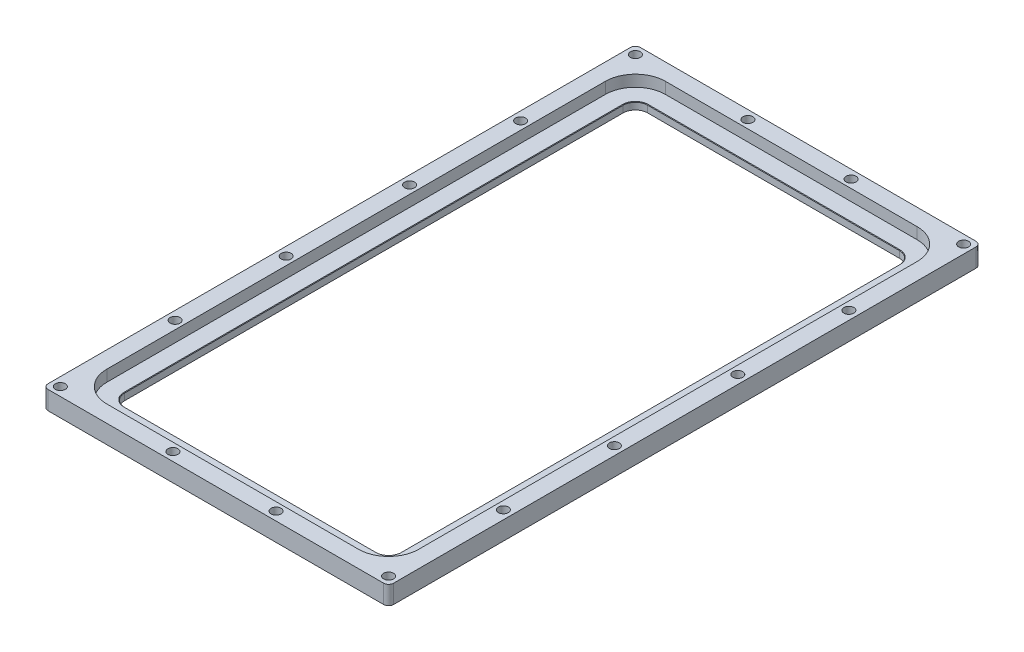
from build123d import *

# Parameters (mm, degrees)
SKETCH1_W           = 177.8
SKETCH1_H           = 304.8
BOSS_EXTRUDE1_DEPTH = 9.525
SKETCH2_W           = 142.24
SKETCH2_H           = 269.24
CUT_EXTRUDE1_DEPTH  = 10.525
SKETCH3_R           = 2.5527
CUT_EXTRUDE2_DEPTH  = 10.525
FILLET4_R           = 6.35
CUT_EXTRUDE5_DEPTH  = 5.842
CHAMFER1_SIZE       = 0.254
FILLET5_R           = 2.54


with BuildPart() as part:
    # Sketch1 → Boss-Extrude1 (new body)
    with BuildSketch(Plane(origin=(0, 0, 0), x_dir=(1, 0, 0), z_dir=(0, 1, 0))):
        with Locations((88.9, 152.4)):
            Rectangle(SKETCH1_W, SKETCH1_H)
    extrude(amount=BOSS_EXTRUDE1_DEPTH)

    # Sketch2 → Cut-Extrude1 (cut, through all)
    with BuildSketch(Plane(origin=(0, 9.525, 0), x_dir=(1, 0, 0), z_dir=(0, 1, 0))):
        with Locations((88.9, 152.4)):
            Rectangle(SKETCH2_W, SKETCH2_H)
    extrude(amount=-CUT_EXTRUDE1_DEPTH, mode=Mode.SUBTRACT)

    # Sketch3 → Cut-Extrude2 (cut, through all)
    with BuildSketch(Plane(origin=(0, 9.525, 0), x_dir=(1, 0, 0), z_dir=(0, 1, 0))):
        with Locations((4.445, 184.15)):
            Circle(SKETCH3_R)
        with Locations((4.445, 241.3)):
            Circle(SKETCH3_R)
        with Locations((62.357, 300.355)):
            Circle(SKETCH3_R)
        with Locations((4.445, 300.355)):
            Circle(SKETCH3_R)
        with Locations((173.355, 184.15)):
            Circle(SKETCH3_R)
        with Locations((173.355, 241.3)):
            Circle(SKETCH3_R)
        with Locations((173.355, 300.355)):
            Circle(SKETCH3_R)
        with Locations((115.443, 300.355)):
            Circle(SKETCH3_R)
        with Locations((173.355, 120.65)):
            Circle(SKETCH3_R)
        with Locations((173.355, 63.5)):
            Circle(SKETCH3_R)
        with Locations((173.355, 4.445)):
            Circle(SKETCH3_R)
        with Locations((115.443, 4.445)):
            Circle(SKETCH3_R)
        with Locations((62.357, 4.445)):
            Circle(SKETCH3_R)
        with Locations((4.445, 4.445)):
            Circle(SKETCH3_R)
        with Locations((4.445, 63.5)):
            Circle(SKETCH3_R)
        with Locations((4.445, 120.65)):
            Circle(SKETCH3_R)
    extrude(amount=-CUT_EXTRUDE2_DEPTH, mode=Mode.SUBTRACT)

    # Fillet4
    fillet4_edges = [part.edges().sort_by_distance(p)[0] for p in [
        (17.78, 4.7625, -17.78),
        (17.78, 4.7625, -287.02),
        (160.02, 4.7625, -287.02),
        (160.02, 4.7625, -17.78),
    ]]
    fillet(fillet4_edges, radius=FILLET4_R)

    # Sketch7 → Cut-Extrude5 (cut)
    with BuildSketch(Plane(origin=(0, 9.525, 0), x_dir=(1, 0, 0), z_dir=(0, 1, 0))):
        with BuildLine():
            Line((8.636, 280.67), (8.636, 24.13))
            ThreePointArc((8.636, 24.13), (13.174087532, 13.174087532), (24.13, 8.636))
            Line((24.13, 8.636), (153.67, 8.636))
            ThreePointArc((153.67, 8.636), (164.625912468, 13.174087532), (169.164, 24.13))
            Line((169.164, 24.13), (169.164, 280.67))
            ThreePointArc((169.164, 280.67), (164.625912468, 291.625912468), (153.67, 296.164))
            Line((153.67, 296.164), (24.13, 296.164))
            ThreePointArc((24.13, 296.164), (13.174087532, 291.625912468), (8.636, 280.67))
        make_face()
        with BuildLine():
            Line((24.13, 17.78), (153.67, 17.78))
            ThreePointArc((153.67, 17.78), (158.160128061, 19.639871939), (160.02, 24.13))
            Line((160.02, 24.13), (160.02, 280.67))
            ThreePointArc((160.02, 280.67), (158.160128061, 285.160128061), (153.67, 287.02))
            Line((153.67, 287.02), (24.13, 287.02))
            ThreePointArc((24.13, 287.02), (19.639871939, 285.160128061), (17.78, 280.67))
            Line((17.78, 280.67), (17.78, 24.13))
            ThreePointArc((17.78, 24.13), (19.639871939, 19.639871939), (24.13, 17.78))
        make_face(mode=Mode.SUBTRACT)
    extrude(amount=-CUT_EXTRUDE5_DEPTH, mode=Mode.SUBTRACT)

    # Chamfer1
    chamfer1_edges = [part.edges().sort_by_distance(p)[0] for p in [
        (17.78, 3.683, -152.4),
        (19.639871939, 3.683, -19.639871939),
        (88.9, 3.683, -17.78),
        (158.160128061, 3.683, -19.639871939),
        (160.02, 3.683, -152.4),
        (158.160128061, 3.683, -285.160128061),
        (88.9, 3.683, -287.02),
        (19.639871939, 3.683, -285.160128061),
    ]]
    chamfer(chamfer1_edges, length=CHAMFER1_SIZE)

    # Fillet5
    fillet5_edges = [part.edges().sort_by_distance(p)[0] for p in [
        (0, 4.7625, -304.8),
        (177.8, 4.7625, -304.8),
        (177.8, 4.7625, 0),
        (0, 4.7625, 0),
    ]]
    fillet(fillet5_edges, radius=FILLET5_R)


solid = part.part
